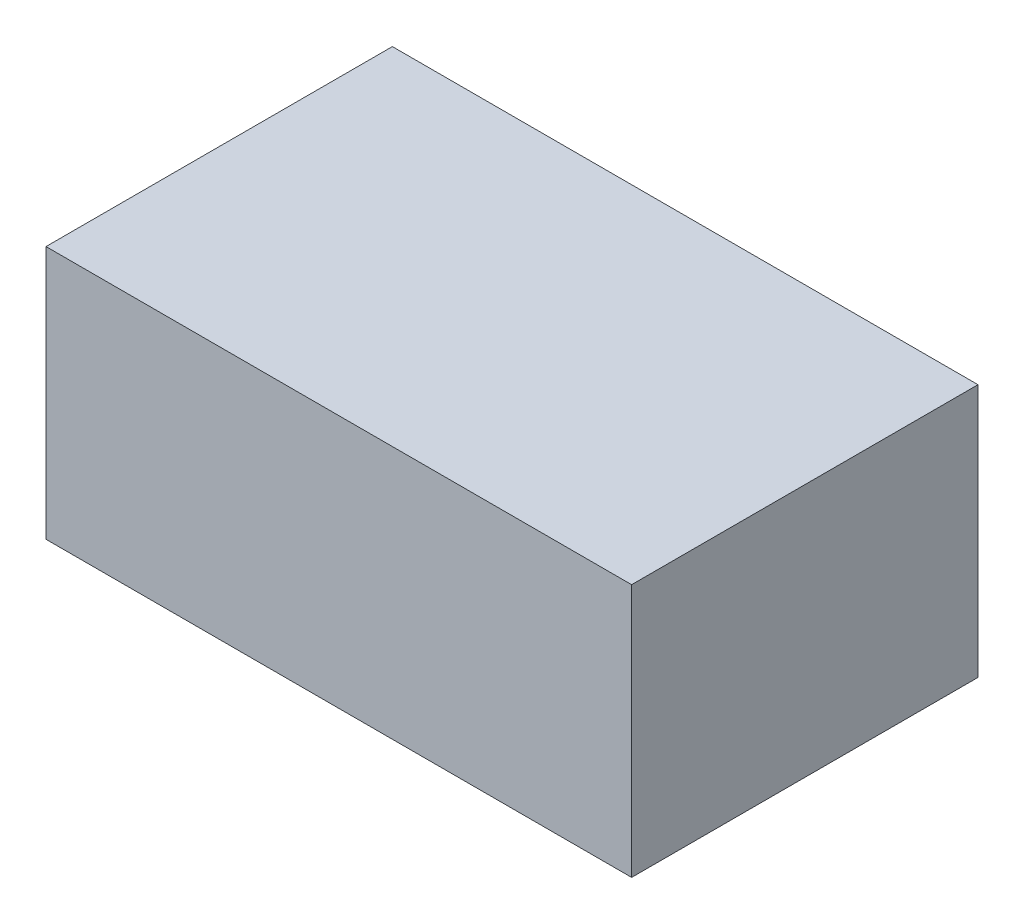
from build123d import *

# Parameters (mm, degrees)
SKETCH1_W      = 984
SKETCH1_H      = 582
EXTRUDE1_DEPTH = 426


with BuildPart() as part:
    # Sketch1 → Extrude1 (new body)
    with BuildSketch(Plane(origin=(0, 0, 0), x_dir=(1, 0, 0), z_dir=(0, 1, 0))):
        with Locations((492, 291)):
            Rectangle(SKETCH1_W, SKETCH1_H)
    extrude(amount=EXTRUDE1_DEPTH)


solid = part.part
